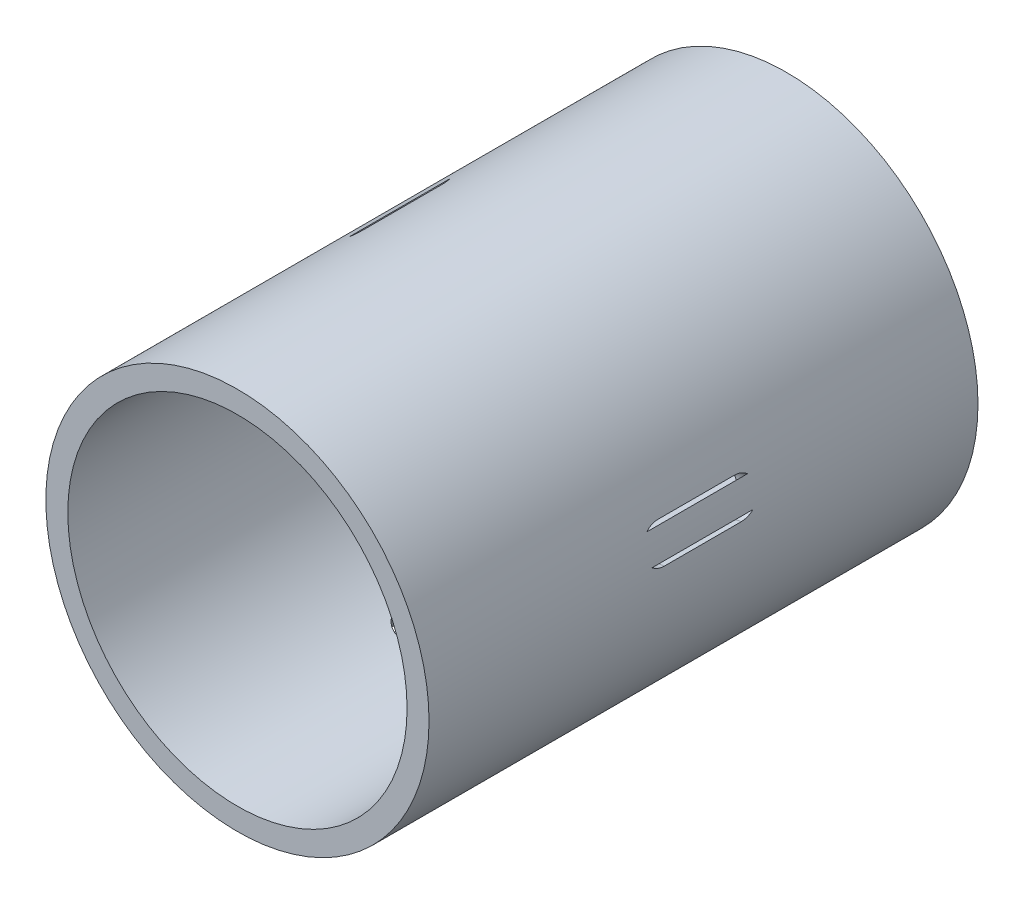
from build123d import *

# Parameters (mm, degrees)
ESQUISSE1_R                  = 17.45
ESQUISSE1_R_2                = 15.45
BOSS_EXTRU_1_DEPTH           = 50
ENL_V_MAT_EXTRU_1_REACH      = 66.713
ENL_V_MAT_EXTRU_2_REACH      = 66.175
ENL_V_MAT_EXTRU_3_REACH      = 67.328
ENL_V_MAT_EXTRU_3_END_RADIUS = 15.45


with BuildPart() as part:
    # Esquisse1 → Boss.-Extru.1 (new body)
    with BuildSketch(Plane.XY):
        Circle(ESQUISSE1_R)
        Circle(ESQUISSE1_R_2, mode=Mode.SUBTRACT)
    extrude(amount=-BOSS_EXTRU_1_DEPTH)

    # Esquisse2 → Enlèv. mat.-Extru.1 (cut, up to next)
    with BuildSketch(Plane(origin=(-5.845108935, -16.388859068, 0), x_dir=(-0.9418884521644214, 0.3359258008538648, 0), z_dir=(-0.3359258008538648, -0.9418884521644214, 0)), mode=Mode.PRIVATE) as enl_v_mat_extru_1_sk1:
        with BuildLine():
            Line((1.7, 28.5), (1.7, 21.5))
            ThreePointArc((1.7, 21.5), (0, 19.8), (-1.7, 21.5))
            Line((-1.7, 21.5), (-1.7, 28.5))
            ThreePointArc((-1.7, 28.5), (0, 30.2), (1.7, 28.5))
        make_face()
    enl_v_mat_extru_1_tool1 = extrude(enl_v_mat_extru_1_sk1.sketch, amount=-ENL_V_MAT_EXTRU_1_REACH, mode=Mode.PRIVATE) & part.part
    add(enl_v_mat_extru_1_tool1.solids().sort_by_distance((-5.845109, -16.388859, -25))[0], mode=Mode.SUBTRACT)

    # Esquisse4 → Enlèv. mat.-Extru.2 (cut, up to next)
    with BuildSketch(Plane(origin=(17.115722759, 3.132416708, 0), x_dir=(0, 0, 1), z_dir=(0.9836622275325246, 0.18002394875613614, 0)), mode=Mode.PRIVATE) as enl_v_mat_extru_2_sk1:
        with BuildLine():
            Line((-28.5, 1.71), (-21.5, 1.71))
            ThreePointArc((-21.5, 1.71), (-19.79, 0), (-21.5, -1.71))
            Line((-21.5, -1.71), (-28.5, -1.71))
            ThreePointArc((-28.5, -1.71), (-30.21, 0), (-28.5, 1.71))
        make_face()
    enl_v_mat_extru_2_tool1 = extrude(enl_v_mat_extru_2_sk1.sketch, amount=-ENL_V_MAT_EXTRU_2_REACH, mode=Mode.PRIVATE) & part.part
    add(enl_v_mat_extru_2_tool1.solids().sort_by_distance((17.115723, 3.132417, -25))[0], mode=Mode.SUBTRACT)

    # Enlèv. mat.-Extru.3: up to this cylinder (the profile starts outside it)
    enl_v_mat_extru_3_end = Plane(origin=(0, 0, -25), z_dir=(0, 0, 1)) * Cylinder(ENL_V_MAT_EXTRU_3_END_RADIUS, 166.556, mode=Mode.PRIVATE)
    # Esquisse5 → Enlèv. mat.-Extru.3 (cut, up to the surface)
    with BuildSketch(Plane(origin=(-11.270613824, 13.256442359, 0), x_dir=(0, 0, 1), z_dir=(-0.6477364266786677, 0.761864503408284, 0)), mode=Mode.PRIVATE) as enl_v_mat_extru_3_sk1:
        with BuildLine():
            Line((-28.5, 1.72), (-21.5, 1.72))
            ThreePointArc((-21.5, 1.72), (-19.78, 0), (-21.5, -1.72))
            Line((-21.5, -1.72), (-28.5, -1.72))
            ThreePointArc((-28.5, -1.72), (-30.22, 0), (-28.5, 1.72))
        make_face()
    enl_v_mat_extru_3_tool1 = extrude(enl_v_mat_extru_3_sk1.sketch, amount=-ENL_V_MAT_EXTRU_3_REACH, mode=Mode.PRIVATE) - enl_v_mat_extru_3_end
    add(enl_v_mat_extru_3_tool1.solids().sort_by_distance((-11.270614, 13.256442, -25))[0], mode=Mode.SUBTRACT)


solid = part.part
